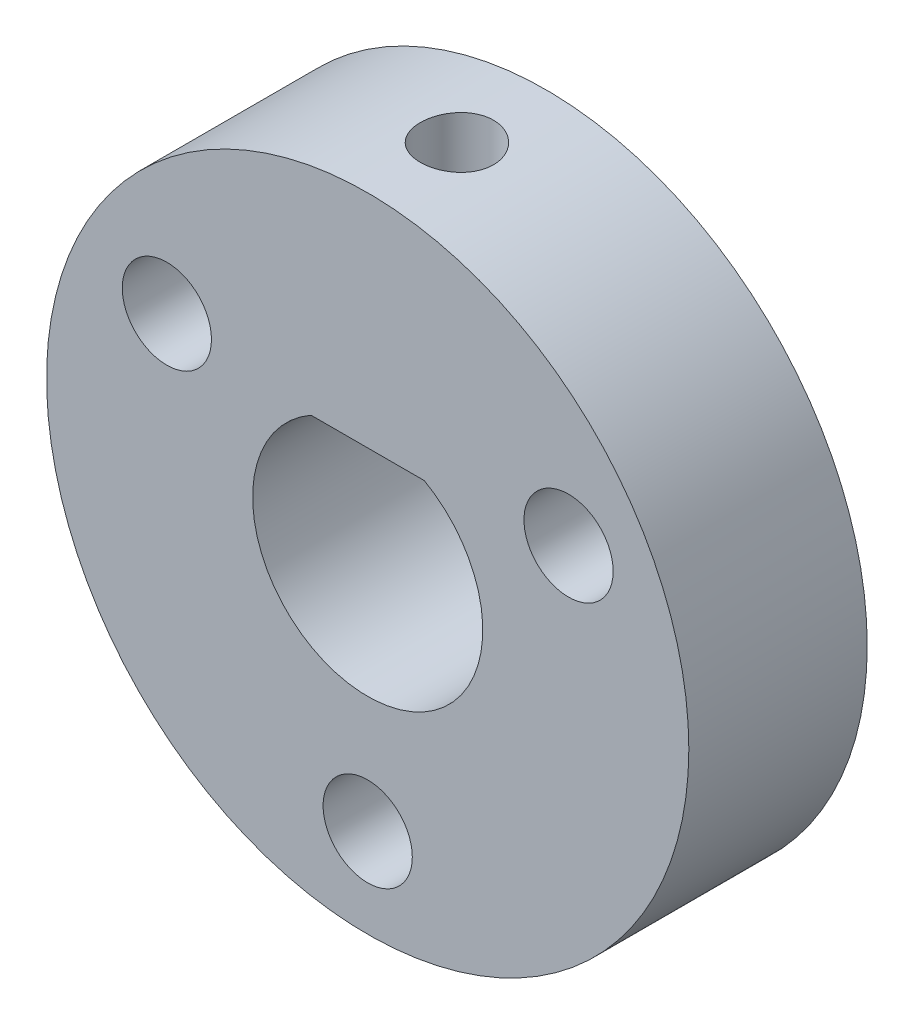
from build123d import *

# Parameters (mm, degrees)
SKETCH1_R              = 9
BOSS_EXTRUDE1_DEPTH    = 2.5
M2_5_CLEARANCE_HOLE2_D = 2.5
CIRPATTERN1_COUNT      = 3
SKETCH7_W              = 1.025
SKETCH7_H              = 6.192782739


with BuildPart() as part:
    # Sketch1 → Boss-Extrude1 (new body, symmetric)
    with BuildSketch(Plane.XY):
        Circle(SKETCH1_R)
        with BuildLine():
            Line((-1.5875, 2.807217261), (1.5875, 2.807217261))
            ThreePointArc((1.5875, 2.807217261), (0, -3.225), (-1.5875, 2.807217261))
        make_face(mode=Mode.SUBTRACT)
    extrude(amount=BOSS_EXTRUDE1_DEPTH, both=True)

    # M2.5 Clearance Hole2 (through all)
    with Locations(Plane.XY.offset(2.5)):
        with Locations((0, -6.5)):
            m2_5_clearance_hole2 = Hole(M2_5_CLEARANCE_HOLE2_D / 2)

    # CirPattern1: M2.5 Clearance Hole2 ×3 about axis
    cirpattern1_axis = Axis((0, 0, 0), (0, 0, 1))
    for i in range(1, CIRPATTERN1_COUNT):
        add(m2_5_clearance_hole2.rotate(cirpattern1_axis, i * 360 / CIRPATTERN1_COUNT), mode=Mode.SUBTRACT)

    # Sketch7 → M2.5x0.45 Tapped Hole1 (revolve, cut)
    with BuildSketch(Plane(origin=(0, 2.807217261, 0), x_dir=(0, 0, -1), z_dir=(1, 0, 0))):
        with Locations((0.5125, 3.09639137)):
            Rectangle(SKETCH7_W, SKETCH7_H)
    revolve(axis=Axis((0, -3.542782739, 0), (0, 1, 0)), mode=Mode.SUBTRACT)


solid = part.part
